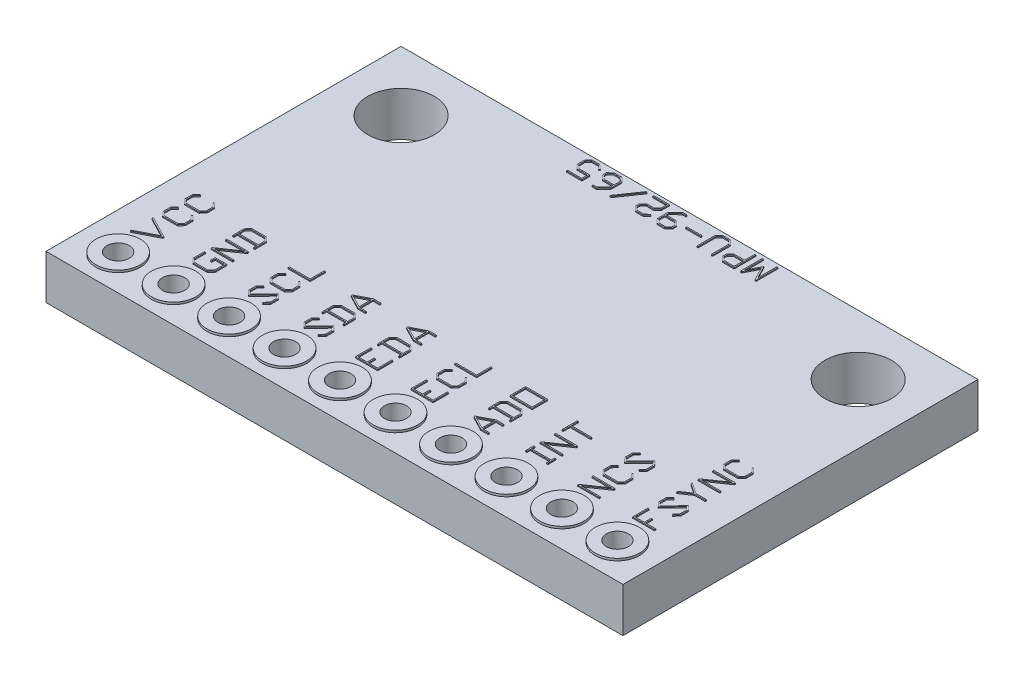
from build123d import *

# Parameters (mm, degrees)
CROQUIS1_W              = 26
CROQUIS1_H              = 16
CROQUIS1_R              = 1.5
SALIENTE_EXTRUIR1_DEPTH = 2
CROQUIS1_3_R            = 0.5
CORTAR_EXTRUIR1_DEPTH   = 2
CROQUIS1_4_R            = 1
CROQUIS1_4_R_2          = 0.5
SALIENTE_EXTRUIR2_DEPTH = 0.1
CROQUIS2_W              = 1
CROQUIS2_H              = 0.706459847
CROQUIS2_W_2            = 0.894561163
CROQUIS2_H_2            = 0.596505007
SALIENTE_EXTRUIR5_DEPTH = 0.05
CROQUIS6_W              = 0.684468879
CROQUIS6_H              = 0.053602984
SALIENTE_EXTRUIR6_DEPTH = 0.05


with BuildPart() as part:
    # Croquis1 → Saliente-Extruir1 (new body)
    with BuildSketch(Plane(origin=(0, 0, 0), x_dir=(1, 0, 0), z_dir=(0, 1, 0))):
        Rectangle(CROQUIS1_W, CROQUIS1_H)
        with Locations((-10.3, 5.3)):
            Circle(CROQUIS1_R, mode=Mode.SUBTRACT)
        with Locations((10.3, 5.3)):
            Circle(CROQUIS1_R, mode=Mode.SUBTRACT)
    extrude(amount=-SALIENTE_EXTRUIR1_DEPTH)

    # Croquis1_3 → Cortar-Extruir1 (cut)
    with BuildSketch(Plane(origin=(0, 0, 0), x_dir=(1, 0, 0), z_dir=(0, 1, 0))):
        with Locations((11.25, -6.5)):
            Circle(CROQUIS1_3_R)
        with Locations((8.75, -6.5)):
            Circle(CROQUIS1_3_R)
        with Locations((6.25, -6.5)):
            Circle(CROQUIS1_3_R)
        with Locations((3.75, -6.5)):
            Circle(CROQUIS1_3_R)
        with Locations((1.25, -6.5)):
            Circle(CROQUIS1_3_R)
        with Locations((-1.25, -6.5)):
            Circle(CROQUIS1_3_R)
        with Locations((-3.75, -6.5)):
            Circle(CROQUIS1_3_R)
        with Locations((-6.25, -6.5)):
            Circle(CROQUIS1_3_R)
        with Locations((-8.75, -6.5)):
            Circle(CROQUIS1_3_R)
        with Locations((-11.25, -6.5)):
            Circle(CROQUIS1_3_R)
    extrude(amount=-CORTAR_EXTRUIR1_DEPTH, mode=Mode.SUBTRACT)

    # Croquis1_4 → Saliente-Extruir2 (add)
    with BuildSketch(Plane(origin=(0, 0, 0), x_dir=(1, 0, 0), z_dir=(0, 1, 0))):
        with Locations((-8.75, -6.5)):
            Circle(CROQUIS1_4_R)
        with Locations((-8.75, -6.5)):
            Circle(CROQUIS1_4_R_2, mode=Mode.SUBTRACT)
        with Locations((-11.25, -6.5)):
            Circle(CROQUIS1_4_R)
        with Locations((-11.25, -6.5)):
            Circle(CROQUIS1_4_R_2, mode=Mode.SUBTRACT)
        with Locations((-6.25, -6.5)):
            Circle(CROQUIS1_4_R)
        with Locations((-6.25, -6.5)):
            Circle(CROQUIS1_4_R_2, mode=Mode.SUBTRACT)
        with Locations((-3.75, -6.5)):
            Circle(CROQUIS1_4_R)
        with Locations((-3.75, -6.5)):
            Circle(CROQUIS1_4_R_2, mode=Mode.SUBTRACT)
        with Locations((-1.25, -6.5)):
            Circle(CROQUIS1_4_R)
        with Locations((-1.25, -6.5)):
            Circle(CROQUIS1_4_R_2, mode=Mode.SUBTRACT)
        with Locations((1.25, -6.5)):
            Circle(CROQUIS1_4_R)
        with Locations((1.25, -6.5)):
            Circle(CROQUIS1_4_R_2, mode=Mode.SUBTRACT)
        with Locations((3.75, -6.5)):
            Circle(CROQUIS1_4_R)
        with Locations((3.75, -6.5)):
            Circle(CROQUIS1_4_R_2, mode=Mode.SUBTRACT)
        with Locations((6.25, -6.5)):
            Circle(CROQUIS1_4_R)
        with Locations((6.25, -6.5)):
            Circle(CROQUIS1_4_R_2, mode=Mode.SUBTRACT)
        with Locations((8.75, -6.5)):
            Circle(CROQUIS1_4_R)
        with Locations((8.75, -6.5)):
            Circle(CROQUIS1_4_R_2, mode=Mode.SUBTRACT)
        with Locations((11.25, -6.5)):
            Circle(CROQUIS1_4_R)
        with Locations((11.25, -6.5)):
            Circle(CROQUIS1_4_R_2, mode=Mode.SUBTRACT)
    saliente_extruir2 = extrude(amount=SALIENTE_EXTRUIR2_DEPTH)

    # Croquis2 → Saliente-Extruir5 (add)
    with BuildSketch(Plane(origin=(0, 0, 0), x_dir=(1, 0, 0), z_dir=(0, 1, 0))):
        Polygon((-11.840020971, -4.319144082), (-10.875167251, -4.817475125), (-10.875167251, -4.861849756), (-11.840020971, -5.358806364), (-11.866527942, -5.311879209), (-10.949975811, -4.839269745), (-11.865938898, -4.367445672), align=None)
        Polygon((-11.040884902, -3.338189831), (-10.865153506, -3.5211861), (-10.865153506, -3.868329238), (-11.038136031, -4.047987593), (-11.690992894, -4.047987593), (-11.865153506, -3.868329238), (-11.865153506, -3.5211861), (-11.688244023, -3.338189831), (-11.65054522, -3.377459417), (-11.812139566, -3.542980721), (-11.812139566, -3.847123662), (-11.670376361, -3.993010173), (-11.058752564, -3.993010173), (-10.917578403, -3.847123662), (-10.917578403, -3.542980721), (-11.078583705, -3.377459417), align=None)
        Polygon((-11.040884902, -2.358020972), (-10.865153506, -2.541017241), (-10.865153506, -2.888160379), (-11.038136031, -3.067818733), (-11.690992894, -3.067818733), (-11.865153506, -2.888160379), (-11.865153506, -2.541017241), (-11.688244023, -2.358020972), (-11.65054522, -2.397290558), (-11.812139566, -2.562811861), (-11.812139566, -2.866954803), (-11.670376361, -3.012841314), (-11.058752564, -3.012841314), (-10.917578403, -2.866954803), (-10.917578403, -2.562811861), (-11.078583705, -2.397290558), align=None)
        Polygon((-8.365153506, -4.485058082), (-8.365153506, -5.011859574), (-8.538136031, -5.191517928), (-9.190992894, -5.191517928), (-9.365153506, -5.011859574), (-9.365153506, -4.496446261), (-9.312139566, -4.496446261), (-9.312139566, -4.990653998), (-9.170376361, -5.136540508), (-8.558752564, -5.136540508), (-8.417578403, -4.990653998), (-8.417578403, -4.540035502), (-8.83776297, -4.540035502), (-8.83776297, -4.692597842), (-8.891365955, -4.692597842), (-8.891365955, -4.485058082), align=None)
        Polygon((-8.375167251, -3.504889222), (-8.375167251, -3.553387161), (-9.251271708, -4.156371649), (-8.375167251, -4.156371649), (-8.375167251, -4.211349069), (-9.353372631, -4.211349069), (-9.354550718, -4.162262087), (-8.478642609, -3.559866642), (-9.354550718, -3.559866642), (-9.354550718, -3.504889222), align=None)
        Polygon((-8.538136031, -2.524720363), (-8.365153506, -2.704378718), (-8.365153506, -3.220577422), (-8.417578403, -3.220577422), (-8.417578403, -3.068211429), (-9.312139566, -3.068211429), (-9.312139566, -3.220577422), (-9.365153506, -3.220577422), (-9.365153506, -2.704378718), (-9.190992894, -2.524720363), align=None)
        Polygon((-8.558752564, -2.579697783), (-9.170376361, -2.579697783), (-9.312139566, -2.726173338), (-9.312139566, -3.013823053), (-8.417578403, -3.013823053), (-8.417578403, -2.726173338), align=None, mode=Mode.SUBTRACT)
        Polygon((-6.048738819, -4.47386625), (-5.865153506, -4.664127392), (-5.865153506, -5.011859574), (-6.040884902, -5.195444887), (-6.078583705, -5.156371649), (-5.917578403, -4.990064954), (-5.917578403, -4.686511056), (-6.048738819, -4.55063829), (-6.680390105, -5.202120717), (-6.865153506, -5.011859574), (-6.865153506, -4.664127392), (-6.688244023, -4.481131123), (-6.65054522, -4.520989753), (-6.812139566, -4.686511056), (-6.812139566, -4.990064954), (-6.680390105, -5.125348677), align=None)
        Polygon((-6.040884902, -3.501551308), (-5.865153506, -3.684547577), (-5.865153506, -4.031690715), (-6.038136031, -4.211349069), (-6.690992894, -4.211349069), (-6.865153506, -4.031690715), (-6.865153506, -3.684547577), (-6.688244023, -3.501551308), (-6.65054522, -3.540820893), (-6.812139566, -3.706342197), (-6.812139566, -4.010485138), (-6.670376361, -4.156371649), (-6.058752564, -4.156371649), (-5.917578403, -4.010485138), (-5.917578403, -3.706342197), (-6.078583705, -3.540820893), align=None)
        Polygon((-5.865153506, -2.536108543), (-5.865153506, -3.23118021), (-6.854550718, -3.23118021), (-6.854550718, -3.17620279), (-5.917578403, -3.17620279), (-5.917578403, -2.536108543), align=None)
        Polygon((-3.548738819, -4.47386625), (-3.365153506, -4.664127392), (-3.365153506, -5.011859574), (-3.540884902, -5.195444887), (-3.578583705, -5.156371649), (-3.417578403, -4.990064954), (-3.417578403, -4.686511056), (-3.548738819, -4.55063829), (-4.180390105, -5.202120717), (-4.365153506, -5.011859574), (-4.365153506, -4.664127392), (-4.188244023, -4.481131123), (-4.15054522, -4.520989753), (-4.312139566, -4.686511056), (-4.312139566, -4.990064954), (-4.180390105, -5.125348677), align=None)
        Polygon((-3.538136031, -3.504889222), (-3.365153506, -3.684547577), (-3.365153506, -4.200746281), (-3.417578403, -4.200746281), (-3.417578403, -4.048380289), (-4.312139566, -4.048380289), (-4.312139566, -4.200746281), (-4.365153506, -4.200746281), (-4.365153506, -3.684547577), (-4.190992894, -3.504889222), align=None)
        Polygon((-3.558752564, -3.559866642), (-4.170376361, -3.559866642), (-4.312139566, -3.706342197), (-4.312139566, -3.993991912), (-3.417578403, -3.993991912), (-3.417578403, -3.706342197), align=None, mode=Mode.SUBTRACT)
        Polygon((-3.375167251, -2.524720363), (-3.375167251, -2.579697783), (-3.680684627, -2.579697783), (-3.680684627, -3.17620279), (-3.375167251, -3.17620279), (-3.375167251, -3.23118021), (-3.713082036, -3.23118021), (-4.354550718, -2.900530298), (-4.354550718, -2.855370275), (-3.713082036, -2.524720363), align=None)
        Polygon((-3.733109524, -2.596387357), (-4.279153114, -2.877950287), (-3.733109524, -3.159709564), align=None, mode=Mode.SUBTRACT)
        Polygon((-0.865153506, -4.496446261), (-0.865153506, -5.191517928), (-1.865153506, -5.191517928), (-1.865153506, -4.496446261), (-1.812139566, -4.496446261), (-1.812139566, -5.136540508), (-1.391365955, -5.136540508), (-1.391365955, -4.821794779), (-1.33776297, -4.821794779), (-1.33776297, -5.136540508), (-0.917578403, -5.136540508), (-0.917578403, -4.496446261), align=None)
        Polygon((-1.038136031, -3.504889222), (-0.865153506, -3.684547577), (-0.865153506, -4.200746281), (-0.917578403, -4.200746281), (-0.917578403, -4.048380289), (-1.812139566, -4.048380289), (-1.812139566, -4.200746281), (-1.865153506, -4.200746281), (-1.865153506, -3.684547577), (-1.690992894, -3.504889222), align=None)
        Polygon((-1.058752564, -3.559866642), (-1.670376361, -3.559866642), (-1.812139566, -3.706342197), (-1.812139566, -3.993991912), (-0.917578403, -3.993991912), (-0.917578403, -3.706342197), align=None, mode=Mode.SUBTRACT)
        Polygon((-0.875167251, -2.524720363), (-0.875167251, -2.579697783), (-1.180684627, -2.579697783), (-1.180684627, -3.17620279), (-0.875167251, -3.17620279), (-0.875167251, -3.23118021), (-1.213082036, -3.23118021), (-1.854550718, -2.900530298), (-1.854550718, -2.855370275), (-1.213082036, -2.524720363), align=None)
        Polygon((-1.233109524, -2.596387357), (-1.779153114, -2.877950287), (-1.233109524, -3.159709564), align=None, mode=Mode.SUBTRACT)
        Polygon((1.634846494, -4.496446261), (1.634846494, -5.191517928), (0.634846494, -5.191517928), (0.634846494, -4.496446261), (0.687860434, -4.496446261), (0.687860434, -5.136540508), (1.108634045, -5.136540508), (1.108634045, -4.821794779), (1.16223703, -4.821794779), (1.16223703, -5.136540508), (1.582421597, -5.136540508), (1.582421597, -4.496446261), align=None)
        Polygon((1.459115098, -3.501551308), (1.634846494, -3.684547577), (1.634846494, -4.031690715), (1.461863969, -4.211349069), (0.809007106, -4.211349069), (0.634846494, -4.031690715), (0.634846494, -3.684547577), (0.811755977, -3.501551308), (0.84945478, -3.540820893), (0.687860434, -3.706342197), (0.687860434, -4.010485138), (0.829623639, -4.156371649), (1.441247436, -4.156371649), (1.582421597, -4.010485138), (1.582421597, -3.706342197), (1.421416295, -3.540820893), align=None)
        Polygon((1.634846494, -2.536108543), (1.634846494, -3.23118021), (0.645449282, -3.23118021), (0.645449282, -3.17620279), (1.582421597, -3.17620279), (1.582421597, -2.536108543), align=None)
        Polygon((4.124832749, -4.485058082), (4.124832749, -4.540035502), (3.819315373, -4.540035502), (3.819315373, -5.136540508), (4.124832749, -5.136540508), (4.124832749, -5.191517928), (3.786917964, -5.191517928), (3.145449282, -4.860868017), (3.145449282, -4.815707993), (3.786917964, -4.485058082), align=None)
        Polygon((3.766890476, -4.556725076), (3.220846886, -4.838288005), (3.766890476, -5.120047282), align=None, mode=Mode.SUBTRACT)
        Polygon((3.961863969, -3.504889222), (4.134846494, -3.684547577), (4.134846494, -4.200746281), (4.082421597, -4.200746281), (4.082421597, -4.048380289), (3.187860434, -4.048380289), (3.187860434, -4.200746281), (3.134846494, -4.200746281), (3.134846494, -3.684547577), (3.309007106, -3.504889222), align=None)
        Polygon((3.941247436, -3.559866642), (3.329623639, -3.559866642), (3.187860434, -3.706342197), (3.187860434, -3.993991912), (4.082421597, -3.993991912), (4.082421597, -3.706342197), align=None, mode=Mode.SUBTRACT)
        with Locations((3.634846494, -2.877950286)):
            Rectangle(CROQUIS2_W, CROQUIS2_H)
        with Locations((3.635141016, -2.877950286)):
            Rectangle(CROQUIS2_W_2, CROQUIS2_H_2, mode=Mode.SUBTRACT)
        Polygon((6.634846494, -4.658433303), (6.634846494, -5.017553664), (6.582421597, -5.017553664), (6.582421597, -4.865187671), (5.687860434, -4.865187671), (5.687860434, -5.017553664), (5.634846494, -5.017553664), (5.634846494, -4.658433303), (5.687860434, -4.658433303), (5.687860434, -4.810799295), (6.582421597, -4.810799295), (6.582421597, -4.658433303), align=None)
        Polygon((6.624832749, -3.668250699), (6.624832749, -3.716748637), (5.748728292, -4.319733126), (6.624832749, -4.319733126), (6.624832749, -4.374710546), (5.646627369, -4.374710546), (5.645449282, -4.325623564), (6.521357391, -3.723228119), (5.645449282, -3.723228119), (5.645449282, -3.668250699), align=None)
        Polygon((5.687860434, -2.69947002), (5.687860434, -3.014215749), (6.624832749, -3.014215749), (6.624832749, -3.069193169), (5.687860434, -3.069193169), (5.687860434, -3.383938898), (5.634846494, -3.383938898), (5.634846494, -2.69947002), align=None)
        Polygon((9.124832749, -4.485058082), (9.124832749, -4.53355602), (8.248728292, -5.136540508), (9.124832749, -5.136540508), (9.124832749, -5.191517928), (8.146627369, -5.191517928), (8.145449282, -5.142430946), (9.021357391, -4.540035502), (8.145449282, -4.540035502), (8.145449282, -4.485058082), align=None)
        Polygon((8.959115098, -3.501551308), (9.134846494, -3.684547577), (9.134846494, -4.031690715), (8.961863969, -4.211349069), (8.309007106, -4.211349069), (8.134846494, -4.031690715), (8.134846494, -3.684547577), (8.311755977, -3.501551308), (8.34945478, -3.540820893), (8.187860434, -3.706342197), (8.187860434, -4.010485138), (8.329623639, -4.156371649), (8.941247436, -4.156371649), (9.082421597, -4.010485138), (9.082421597, -3.706342197), (8.921416295, -3.540820893), align=None)
        Polygon((8.951261181, -2.513528531), (9.134846494, -2.703789674), (9.134846494, -3.051521855), (8.959115098, -3.235107169), (8.921416295, -3.196033931), (9.082421597, -3.029727235), (9.082421597, -2.726173338), (8.951261181, -2.590300571), (8.319609895, -3.241782998), (8.134846494, -3.051521855), (8.134846494, -2.703789674), (8.311755977, -2.520793405), (8.34945478, -2.560652034), (8.187860434, -2.726173338), (8.187860434, -3.029727235), (8.319609895, -3.165010958), align=None)
        Polygon((10.687860434, -4.503797162), (10.687860434, -5.143891409), (11.108634045, -5.143891409), (11.108634045, -4.82914568), (11.16223703, -4.82914568), (11.16223703, -5.143891409), (11.624832749, -5.143891409), (11.624832749, -5.198868829), (10.634846494, -5.198868829), (10.634846494, -4.503797162), align=None)
        Polygon((11.451261181, -3.501048291), (11.634846494, -3.691309434), (11.634846494, -4.039041615), (11.459115098, -4.222626929), (11.421416295, -4.183553691), (11.582421597, -4.017246995), (11.582421597, -3.713693098), (11.451261181, -3.577820331), (10.819609895, -4.229302758), (10.634846494, -4.039041615), (10.634846494, -3.691309434), (10.811755977, -3.508313165), (10.84945478, -3.548171794), (10.687860434, -3.713693098), (10.687860434, -4.017246995), (10.819609895, -4.152530718), align=None)
        Polygon((10.660568072, -2.526180826), (11.142994933, -2.858205173), (11.624832749, -2.858205173), (11.624832749, -2.913182593), (11.142994933, -2.913182593), (10.661353464, -3.244421549), (10.634846494, -3.196709002), (11.088017513, -2.885301187), (10.634846494, -2.574482417), align=None)
        Polygon((11.624832749, -1.551902405), (11.624832749, -1.600400343), (10.748728292, -2.203384832), (11.624832749, -2.203384832), (11.624832749, -2.258362252), (10.646627369, -2.258362252), (10.645449282, -2.209275269), (11.521357391, -1.606879825), (10.645449282, -1.606879825), (10.645449282, -1.551902405), align=None)
        Polygon((11.459115098, -0.568395631), (11.634846494, -0.7513919), (11.634846494, -1.098535038), (11.461863969, -1.278193392), (10.809007106, -1.278193392), (10.634846494, -1.098535038), (10.634846494, -0.7513919), (10.811755977, -0.568395631), (10.84945478, -0.607665216), (10.687860434, -0.77318652), (10.687860434, -1.077329462), (10.829623639, -1.223215972), (11.441247436, -1.223215972), (11.582421597, -1.077329462), (11.582421597, -0.77318652), (11.421416295, -0.607665216), align=None)
    extrude(amount=SALIENTE_EXTRUIR5_DEPTH)

    # Croquis6 → Saliente-Extruir6 (add)
    with BuildSketch(Plane(origin=(0, 0, 0), x_dir=(1, 0, 0), z_dir=(0, 1, 0))):
        Polygon((3.468427253, 7.805301394), (3.523404673, 7.805301394), (3.523404673, 6.955114864), (3.821657177, 7.533555861), (4.11990968, 6.955114864), (4.11990968, 7.805301394), (4.1748871, 7.805301394), (4.1748871, 6.825917927), (4.125211074, 6.825917927), (3.821657177, 7.413587277), (3.518103279, 6.825917927), (3.468427253, 6.825917927), align=None)
        Polygon((2.488258394, 7.168545062), (2.667916748, 7.342705674), (3.139740821, 7.342705674), (3.139740821, 7.805301394), (3.194718241, 7.805301394), (3.194718241, 6.815315138), (2.667916748, 6.815315138), (2.488258394, 6.989475751), align=None)
        Polygon((2.543235814, 7.147339486), (2.543235814, 7.010092284), (2.689711369, 6.868329079), (3.139740821, 6.868329079), (3.139740821, 7.28910269), (2.689711369, 7.28910269), align=None, mode=Mode.SUBTRACT)
        Polygon((1.508089535, 7.642332613), (1.687747889, 7.815315138), (2.034891027, 7.815315138), (2.214549382, 7.642332613), (2.214549382, 6.825917927), (2.159571962, 6.825917927), (2.159571962, 7.621716081), (2.013685451, 7.762890242), (1.709542509, 7.762890242), (1.563066955, 7.621716081), (1.563066955, 6.825917927), (1.508089535, 6.825917927), align=None)
        with Locations((0.881543295, 7.315904182)):
            Rectangle(CROQUIS6_W, CROQUIS6_H)
        Polygon((-0.452248184, 7.483879835), (-0.109621048, 7.815315138), (0.080640094, 7.815315138), (0.080640094, 7.762890242), (-0.088415472, 7.762890242), (-0.397270764, 7.463263303), (-0.397270764, 7.342705674), (0.074553308, 7.342705674), (0.254211663, 7.168545062), (0.254211663, 6.989475751), (0.074553308, 6.815315138), (-0.272589829, 6.815315138), (-0.452248184, 6.989475751), align=None)
        Polygon((-0.397270764, 7.28910269), (-0.397270764, 7.010092284), (-0.250795209, 6.868329079), (0.053347732, 6.868329079), (0.199234243, 7.010092284), (0.199234243, 7.147339486), (0.053347732, 7.28910269), align=None, mode=Mode.SUBTRACT)
        Polygon((-1.432417043, 7.168545062), (-1.253347732, 7.342705674), (-0.927410171, 7.342705674), (-0.780934616, 7.483879835), (-0.780934616, 7.762890242), (-1.421028863, 7.762890242), (-1.421028863, 7.815315138), (-0.725957196, 7.815315138), (-0.725957196, 7.463263303), (-0.905615551, 7.28910269), (-1.230964068, 7.28910269), (-1.377439623, 7.147339486), (-1.377439623, 7.010092284), (-1.230964068, 6.868329079), (-0.927410171, 6.868329079), (-0.761103475, 7.029923424), (-0.722030238, 6.992224622), (-0.905615551, 6.815315138), (-1.253347732, 6.815315138), (-1.432417043, 6.989475751), align=None)
        Polygon((-2.41847634, 6.841036717), (-1.747948164, 7.815315138), (-1.700235618, 7.789397212), (-2.37017475, 6.815315138), align=None)
        Polygon((-3.392754761, 7.642332613), (-3.213096407, 7.815315138), (-2.865953269, 7.815315138), (-2.686294915, 7.642332613), (-2.686294915, 7.147339486), (-3.02892205, 6.815315138), (-3.218397801, 6.815315138), (-3.218397801, 6.868329079), (-3.050127626, 6.868329079), (-2.741272335, 7.168545062), (-2.741272335, 7.28910269), (-3.213096407, 7.28910269), (-3.392754761, 7.463263303), align=None)
        Polygon((-3.337777341, 7.621716081), (-3.337777341, 7.483879835), (-3.191301787, 7.342705674), (-2.741272335, 7.342705674), (-2.741272335, 7.621716081), (-2.887158845, 7.762890242), (-3.191301787, 7.762890242), align=None, mode=Mode.SUBTRACT)
        Polygon((-4.372923621, 7.642332613), (-4.19385431, 7.815315138), (-3.846122128, 7.815315138), (-3.662536815, 7.639583742), (-3.701610053, 7.60188494), (-3.867916748, 7.762890242), (-4.171470646, 7.762890242), (-4.317946201, 7.621716081), (-4.317946201, 7.325427057), (-4.171470646, 7.184449244), (-3.666463774, 7.184449244), (-3.666463774, 6.815315138), (-4.361535441, 6.815315138), (-4.361535441, 6.868329079), (-3.721441194, 6.868329079), (-3.721441194, 7.130649912), (-4.19385431, 7.130649912), (-4.372923621, 7.305006872), align=None)
    extrude(amount=SALIENTE_EXTRUIR6_DEPTH)

    # Simetría1: Saliente-Extruir2 across plane
    add(saliente_extruir2.mirror(Plane(origin=(0, -1, 0), x_dir=(0, 0, 1), z_dir=(0, -1, 0))))


solid = part.part
